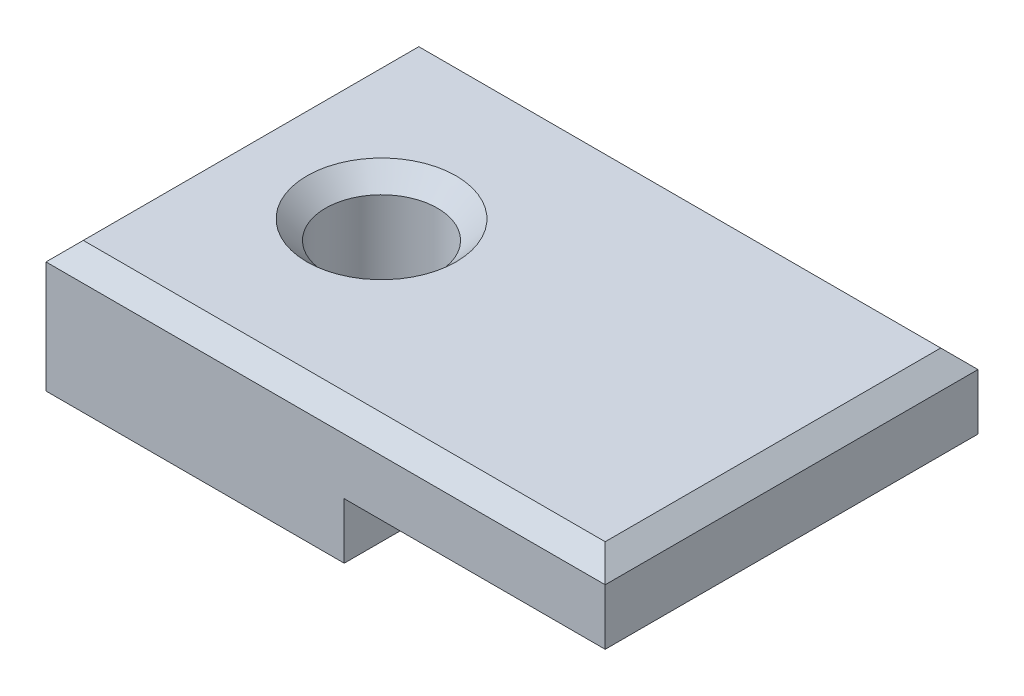
from build123d import *

# Parameters (mm, degrees)
SKETCH1_W           = 30
SKETCH1_H           = 20
SKETCH1_R           = 3
BOSS_EXTRUDE1_DEPTH = 7
SKETCH2_OUTSIDE_W   = 39.346
SKETCH2_OUTSIDE_H   = 29.346
SKETCH2_OUTSIDE_W_2 = 16
SKETCH2_OUTSIDE_H_2 = 20
CUT_EXTRUDE1_DEPTH  = 3
CHAMFER1_SIZE       = 1


with BuildPart() as part:
    # Sketch1 → Boss-Extrude1 (new body)
    with BuildSketch(Plane(origin=(0, 0, 0), x_dir=(1, 0, 0), z_dir=(0, 1, 0))):
        with Locations((7, 0)):
            Rectangle(SKETCH1_W, SKETCH1_H)
        Circle(SKETCH1_R, mode=Mode.SUBTRACT)
    extrude(amount=BOSS_EXTRUDE1_DEPTH)

    # Sketch2 outside → Cut-Extrude1 (cut)
    with BuildSketch(Plane.XZ):
        with Locations((7, 0)):
            Rectangle(SKETCH2_OUTSIDE_W, SKETCH2_OUTSIDE_H)
        Rectangle(SKETCH2_OUTSIDE_W_2, SKETCH2_OUTSIDE_H_2, mode=Mode.SUBTRACT)
    extrude(amount=-CUT_EXTRUDE1_DEPTH, mode=Mode.SUBTRACT)

    # Chamfer1
    chamfer1_edges = [part.edges().sort_by_distance(p)[0] for p in [
        (-3, 7, 0),
        (22, 7, 0),
        (7, 7, -10),
        (-8, 7, 0),
        (7, 7, 10),
    ]]
    chamfer(chamfer1_edges, length=CHAMFER1_SIZE)


solid = part.part
